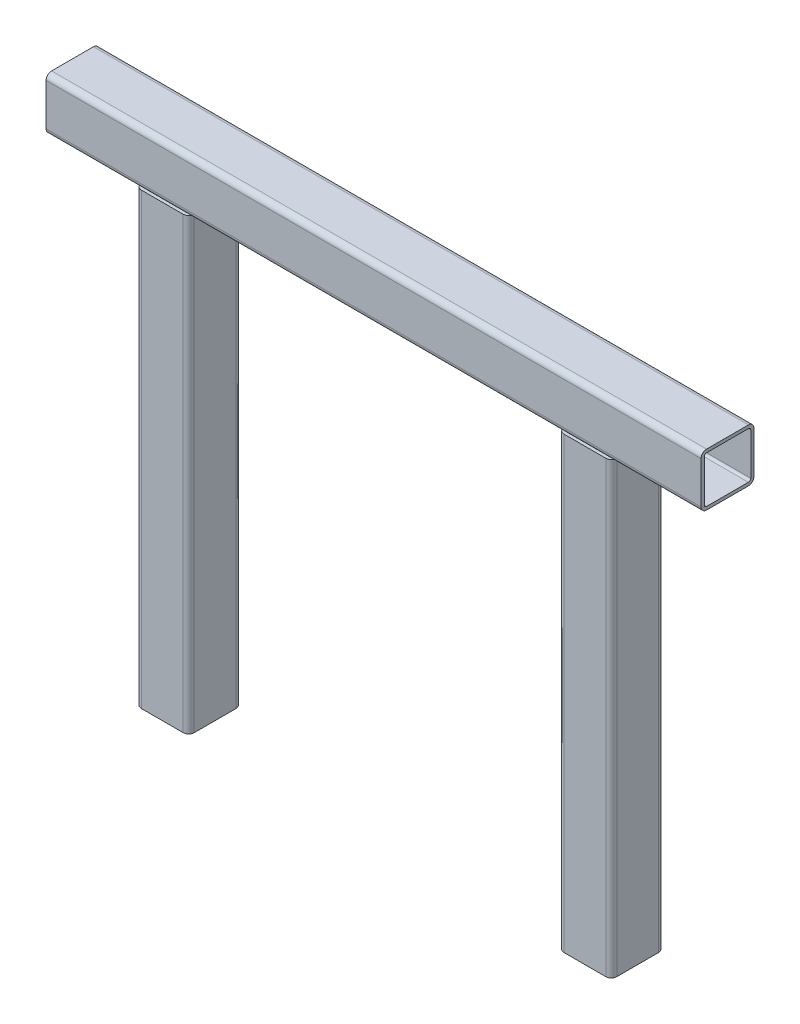
from build123d import *

# Parameters (mm, degrees)
F_50X50XT2_50_X_30_X_2_6_1_DEPTH   = 620
F_50X50XT2_50_X_30_X_2_6_1_2_DEPTH = 451
F_50X50XT2_50_X_30_X_2_6_1_3_DEPTH = 451


with BuildPart() as part:
    # Sketch17 → 50x50xt2 50 X 30 X 2.6(1) (new body)
    with BuildSketch(Plane.YZ.offset(-310)):
        with BuildLine():
            Line((-19.8, -25), (19.8, -25))
            ThreePointArc((19.8, -25), (23.476955262, -23.476955262), (25, -19.8))
            Line((25, -19.8), (25, 19.8))
            ThreePointArc((25, 19.8), (23.476955262, 23.476955262), (19.8, 25))
            Line((19.8, 25), (-19.8, 25))
            ThreePointArc((-19.8, 25), (-23.476955262, 23.476955262), (-25, 19.8))
            Line((-25, 19.8), (-25, -19.8))
            ThreePointArc((-25, -19.8), (-23.476955262, -23.476955262), (-19.8, -25))
        make_face()
        with BuildLine():
            Line((-19.8, -22), (19.8, -22))
            ThreePointArc((19.8, -22), (21.355634919, -21.355634919), (22, -19.8))
            Line((22, -19.8), (22, 19.8))
            ThreePointArc((22, 19.8), (21.355634919, 21.355634919), (19.8, 22))
            Line((19.8, 22), (-19.8, 22))
            ThreePointArc((-19.8, 22), (-21.355634919, 21.355634919), (-22, 19.8))
            Line((-22, 19.8), (-22, -19.8))
            ThreePointArc((-22, -19.8), (-21.355634919, -21.355634919), (-19.8, -22))
        make_face(mode=Mode.SUBTRACT)
    extrude(amount=F_50X50XT2_50_X_30_X_2_6_1_DEPTH)


with BuildPart() as body_2:
    # Sketch17 on segment 2 (carried to segment 2) → 50x50xt2 50 X 30 X 2.6_1 2 (new body)
    with BuildSketch(Plane(origin=(-200, 1, 0), x_dir=(1, 0, 0), z_dir=(0, -1, 0))):
        with BuildLine():
            Line((-19.8, -25), (19.8, -25))
            ThreePointArc((19.8, -25), (23.476955262, -23.476955262), (25, -19.8))
            Line((25, -19.8), (25, 19.8))
            ThreePointArc((25, 19.8), (23.476955262, 23.476955262), (19.8, 25))
            Line((19.8, 25), (-19.8, 25))
            ThreePointArc((-19.8, 25), (-23.476955262, 23.476955262), (-25, 19.8))
            Line((-25, 19.8), (-25, -19.8))
            ThreePointArc((-25, -19.8), (-23.476955262, -23.476955262), (-19.8, -25))
        make_face()
        with BuildLine():
            Line((-19.8, -22), (19.8, -22))
            ThreePointArc((19.8, -22), (21.355634919, -21.355634919), (22, -19.8))
            Line((22, -19.8), (22, 19.8))
            ThreePointArc((22, 19.8), (21.355634919, 21.355634919), (19.8, 22))
            Line((19.8, 22), (-19.8, 22))
            ThreePointArc((-19.8, 22), (-21.355634919, 21.355634919), (-22, 19.8))
            Line((-22, 19.8), (-22, -19.8))
            ThreePointArc((-22, -19.8), (-21.355634919, -21.355634919), (-19.8, -22))
        make_face(mode=Mode.SUBTRACT)
    extrude(amount=F_50X50XT2_50_X_30_X_2_6_1_2_DEPTH)

    # 50x50xt2 50 X 30 X 2.6_1 2 end butt 1
    split(bisect_by=Plane(origin=(-200, -25, 0), x_dir=(1, 0, 0), z_dir=(0, -1, 0)), keep=Keep.TOP)


with BuildPart() as body_3:
    # Sketch17 on segment 3 (carried to segment 3) → 50x50xt2 50 X 30 X 2.6_1 3 (new body)
    with BuildSketch(Plane(origin=(200, 1, 0), x_dir=(1, 0, 0), z_dir=(0, -1, 0))):
        with BuildLine():
            Line((-19.8, -25), (19.8, -25))
            ThreePointArc((19.8, -25), (23.476955262, -23.476955262), (25, -19.8))
            Line((25, -19.8), (25, 19.8))
            ThreePointArc((25, 19.8), (23.476955262, 23.476955262), (19.8, 25))
            Line((19.8, 25), (-19.8, 25))
            ThreePointArc((-19.8, 25), (-23.476955262, 23.476955262), (-25, 19.8))
            Line((-25, 19.8), (-25, -19.8))
            ThreePointArc((-25, -19.8), (-23.476955262, -23.476955262), (-19.8, -25))
        make_face()
        with BuildLine():
            Line((-19.8, -22), (19.8, -22))
            ThreePointArc((19.8, -22), (21.355634919, -21.355634919), (22, -19.8))
            Line((22, -19.8), (22, 19.8))
            ThreePointArc((22, 19.8), (21.355634919, 21.355634919), (19.8, 22))
            Line((19.8, 22), (-19.8, 22))
            ThreePointArc((-19.8, 22), (-21.355634919, 21.355634919), (-22, 19.8))
            Line((-22, 19.8), (-22, -19.8))
            ThreePointArc((-22, -19.8), (-21.355634919, -21.355634919), (-19.8, -22))
        make_face(mode=Mode.SUBTRACT)
    extrude(amount=F_50X50XT2_50_X_30_X_2_6_1_3_DEPTH)

    # 50x50xt2 50 X 30 X 2.6_1 3 end butt 1
    split(bisect_by=Plane(origin=(200, -25, 0), x_dir=(1, 0, 0), z_dir=(0, -1, 0)), keep=Keep.TOP)


solid = Compound([part.part, body_2.part, body_3.part])
